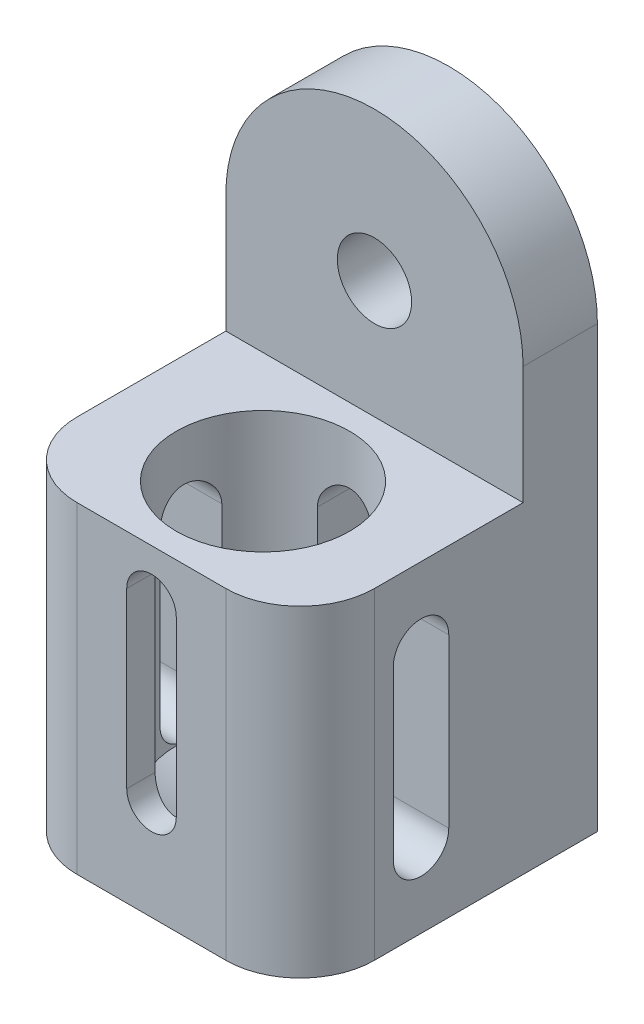
from build123d import *

# Parameters (mm, degrees)
SKETCH1_W                       = 76.2
SKETCH1_H                       = 57.15
BOSS_EXTRUDE1_DEPTH             = 82.55
FILLET1_R                       = 19.05
SKETCH2_W                       = 76.2
SKETCH2_H                       = 19.05
BOSS_EXTRUDE2_DEPTH             = 82.55
CUT_EXTRUDE1_DEPTH              = 38.1
CUT_EXTRUDE2_DEPTH              = 19.05
BOSS_EXTRUDE5_DEPTH             = 19.05
F_1_4_0_75_DIAMETER_HOLE2_D     = 19.05
CUT_EXTRUDE4_REACH              = 120.628
F_1_4_1_75_DIAMETER_HOLE2_D     = 44.45
F_1_4_1_75_DIAMETER_HOLE2_DEPTH = 69.85
F_1_4_1_75_DIAMETER_HOLE2_TIP   = 13.354127258


with BuildPart() as part:
    # Sketch1 → Boss-Extrude1 (new body)
    with BuildSketch(Plane(origin=(0, 0, 0), x_dir=(1, 0, 0), z_dir=(0, 1, 0))):
        Rectangle(SKETCH1_W, SKETCH1_H)
    extrude(amount=-BOSS_EXTRUDE1_DEPTH)

    # Fillet1
    fillet1_edges = [part.edges().sort_by_distance(p)[0] for p in [
        (-38.1, -41.275, 28.575),
        (38.1, -41.275, 28.575),
    ]]
    fillet(fillet1_edges, radius=FILLET1_R)

    # Sketch2 → Boss-Extrude2 (add)
    with BuildSketch(Plane(origin=(0, 0, 0), x_dir=(1, 0, 0), z_dir=(0, 1, 0))):
        with Locations((0, 38.1)):
            Rectangle(SKETCH2_W, SKETCH2_H)
    extrude(amount=-BOSS_EXTRUDE2_DEPTH)

    # Sketch6 → Cut-Extrude1 (cut, symmetric)
    with BuildSketch(Plane(origin=(0, 0, 0), x_dir=(0, 0, -1), z_dir=(1, 0, 0))):
        with BuildLine():
            Line((-4.699, -62.738), (-4.699, -19.812))
            ThreePointArc((-4.699, -19.812), (2.413, -12.7), (9.525, -19.812))
            Line((9.525, -19.812), (9.525, -62.738))
            ThreePointArc((9.525, -62.738), (2.413, -69.85), (-4.699, -62.738))
        make_face()
    extrude(amount=CUT_EXTRUDE1_DEPTH, both=True, mode=Mode.SUBTRACT)

    # Sketch7 → Cut-Extrude2 (cut)
    with BuildSketch(Plane.XY.offset(28.575)):
        with BuildLine():
            Line((6.35, -12.7), (6.35, -57.15))
            ThreePointArc((6.35, -57.15), (0, -63.5), (-6.35, -57.15))
            Line((-6.35, -57.15), (-6.35, -12.7))
            ThreePointArc((-6.35, -12.7), (0, -6.35), (6.35, -12.7))
        make_face()
    extrude(amount=-CUT_EXTRUDE2_DEPTH, mode=Mode.SUBTRACT)

    # Sketch11 → Boss-Extrude5 (add)
    with BuildSketch(Plane(origin=(0, 0, -47.625), x_dir=(-1, 0, 0), z_dir=(0, 0, -1))):
        with BuildLine():
            Line((-38.1, 0), (-38.1, 30.226))
            ThreePointArc((-38.1, 30.226), (0, 68.326), (38.1, 30.226))
            Line((38.1, 30.226), (38.1, 0))
            Line((38.1, 0), (-38.1, 0))
        make_face()
    extrude(amount=-BOSS_EXTRUDE5_DEPTH)

    # 1_4 _0.75_ Diameter Hole2 (through all)
    with Locations(Plane.XY.offset(-28.575)):
        with Locations((0, 30.226)):
            Hole(F_1_4_0_75_DIAMETER_HOLE2_D / 2)

    # Sketch14 → Cut-Extrude4 (cut, up to next)
    with BuildSketch(Plane(origin=(0, 0, -47.625), x_dir=(-1, 0, 0), z_dir=(0, 0, -1)), mode=Mode.PRIVATE) as cut_extrude4_sk1:
        with BuildLine():
            Line((7.112, -19.812), (7.112, -62.738))
            ThreePointArc((7.112, -62.738), (0, -69.85), (-7.112, -62.738))
            Line((-7.112, -62.738), (-7.112, -19.812))
            ThreePointArc((-7.112, -19.812), (0, -12.7), (7.112, -19.812))
        make_face()
    cut_extrude4_tool1 = extrude(cut_extrude4_sk1.sketch, amount=-CUT_EXTRUDE4_REACH, mode=Mode.PRIVATE) & part.part
    add(cut_extrude4_tool1.solids().sort_by_distance((0, -41.275, -47.625))[0], mode=Mode.SUBTRACT)

    # 1_4 _1.75_ Diameter Hole2
    with Locations(Plane(origin=(0, 0, 0), x_dir=(1, 0, 0), z_dir=(0, 1, 0))):
        with Locations((0, 0)):
            Hole(F_1_4_1_75_DIAMETER_HOLE2_D / 2, depth=F_1_4_1_75_DIAMETER_HOLE2_DEPTH)
            with Locations((0, 0, -(F_1_4_1_75_DIAMETER_HOLE2_DEPTH + F_1_4_1_75_DIAMETER_HOLE2_TIP / 2))):  # 118° drill point
                Cone(0, F_1_4_1_75_DIAMETER_HOLE2_D / 2, F_1_4_1_75_DIAMETER_HOLE2_TIP, mode=Mode.SUBTRACT)


solid = part.part
